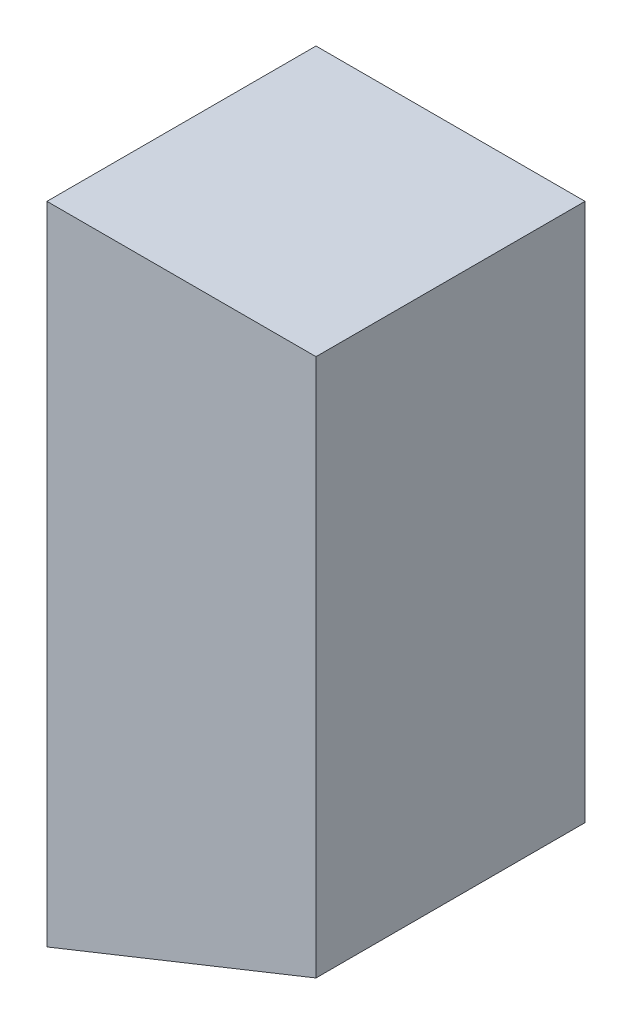
from build123d import *

# Parameters (mm, degrees)
SALIENTE_EXTRUIR1_DEPTH = 0.25


with BuildPart() as part:
    # Croquis1 → Saliente-Extruir1 (new body)
    with BuildSketch(Plane.XY):
        Polygon((0, 0), (0.25, 0), (0.25, -0.5), (0, -0.6), align=None)
    extrude(amount=SALIENTE_EXTRUIR1_DEPTH)


solid = part.part
